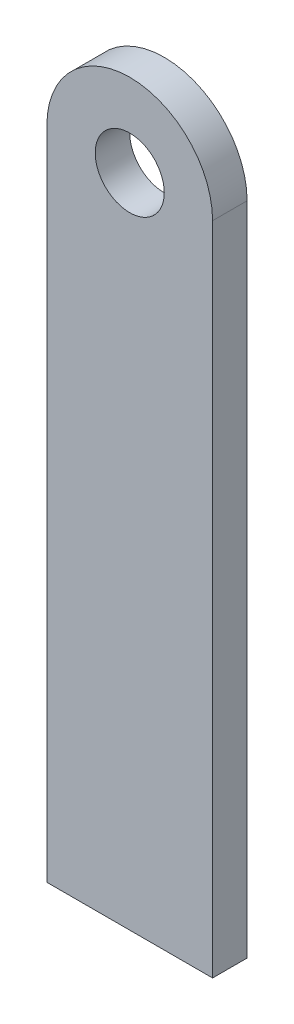
from build123d import *

# Parameters (mm, degrees)
SKETCH1_R           = 3.175
BOSS_EXTRUDE1_DEPTH = 3.175


with BuildPart() as part:
    # Sketch1 → Boss-Extrude1 (new body)
    with BuildSketch(Plane.XY):
        with BuildLine():
            Line((-7.62, 0), (-7.62, -60.325))
            Line((-7.62, -60.325), (7.62, -60.325))
            Line((7.62, -60.325), (7.62, 0))
            ThreePointArc((7.62, 0), (0, 7.62), (-7.62, 0))
        make_face()
        Circle(SKETCH1_R, mode=Mode.SUBTRACT)
    extrude(amount=BOSS_EXTRUDE1_DEPTH)


solid = part.part
